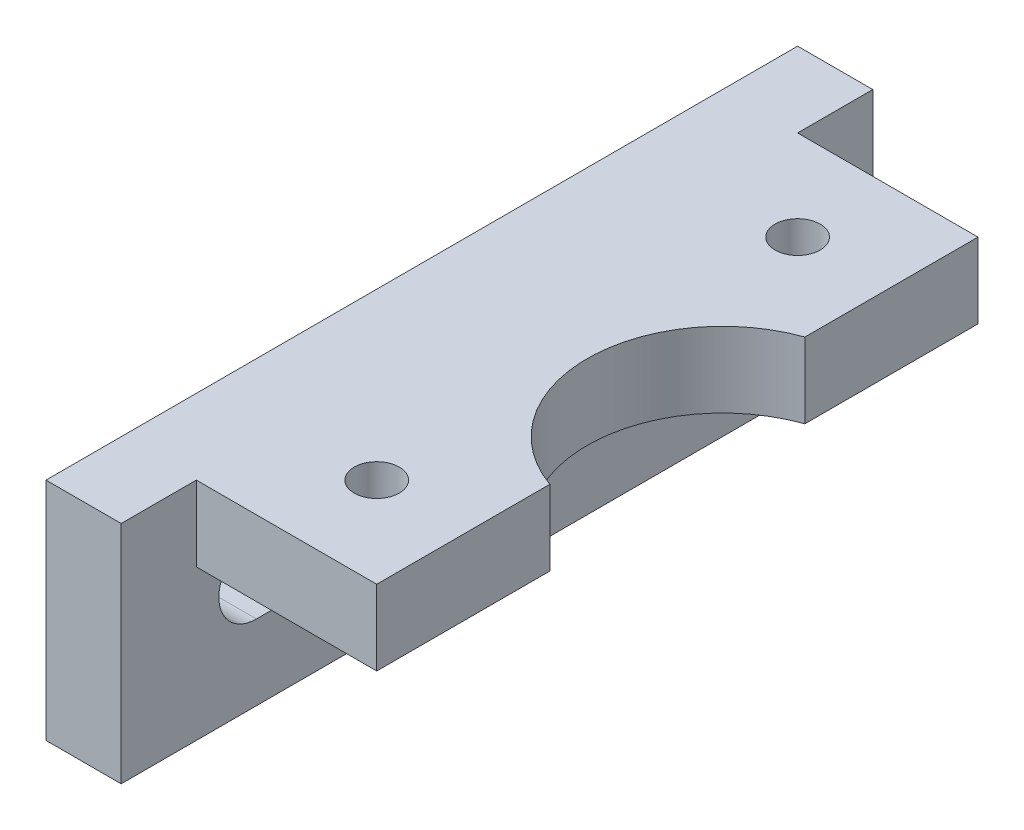
from build123d import *

# Parameters (mm, degrees)
SKETCH_1_W          = 50
SKETCH_1_H          = 15
EXTRUDE_1_DEPTH     = 5
SKETCH_2_W          = 40
SKETCH_2_H          = 5
EXTRUDE_3_DEPTH     = 12
SKETCH_3_R          = 9
SKETCH_3_R_2        = 1.5
CUT_EXTRUDE_1_DEPTH = 16


with BuildPart() as part:
    # 草图1 → 凸台-拉伸1 (new body)
    with BuildSketch(Plane.ZY):
        Rectangle(SKETCH_1_W, SKETCH_1_H)
        with BuildLine():
            Line((-16, 2.5), (16, 2.5))
            ThreePointArc((16, 2.5), (18.5, 0), (16, -2.5))
            Line((16, -2.5), (-16, -2.5))
            ThreePointArc((-16, -2.5), (-18.5, 0), (-16, 2.5))
        make_face(mode=Mode.SUBTRACT)
    extrude(amount=EXTRUDE_1_DEPTH)

    # 草图2 → 凸台-拉伸3 (add)
    with BuildSketch(Plane(origin=(0, 0, 0), x_dir=(0, 0, -1), z_dir=(1, 0, 0))):
        with Locations((0, 5)):
            Rectangle(SKETCH_2_W, SKETCH_2_H)
    extrude(amount=EXTRUDE_3_DEPTH)

    # 草图3 → 切除-拉伸1 (cut, through all)
    with BuildSketch(Plane(origin=(0, 7.5, 0), x_dir=(1, 0, 0), z_dir=(0, 1, 0))):
        with Locations((15, 0)):
            Circle(SKETCH_3_R)
        with Locations((6, 14)):
            Circle(SKETCH_3_R_2)
        with Locations((6, -14)):
            Circle(SKETCH_3_R_2)
    extrude(amount=-CUT_EXTRUDE_1_DEPTH, mode=Mode.SUBTRACT)


solid = part.part
